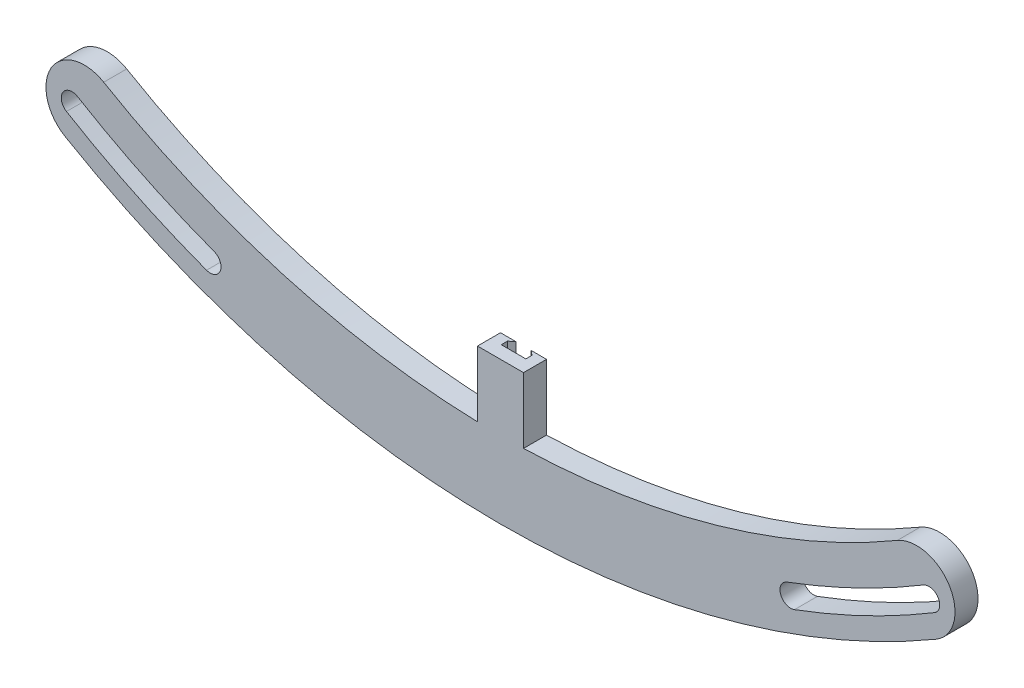
from build123d import *

# Parameters (mm, degrees)
SKETCH1_W           = 3.81
SKETCH1_H           = 12.7
SKETCH2_R           = 1.778
CUT_EXTRUDE1_DEPTH  = 15.24
SKETCH3_R           = 1.778
CUT_EXTRUDE2_DEPTH  = 4.81
SKETCH6_W           = 7.62
SKETCH6_H           = 3.81
BOSS_EXTRUDE1_DEPTH = 10.922
CUT_EXTRUDE3_DEPTH  = 6.096


with BuildPart() as part:
    # Sketch1 → Revolve1 (revolve)
    with BuildSketch(Plane(origin=(0, 0, 0), x_dir=(0, 0, -1), z_dir=(1, 0, 0)), mode=Mode.PRIVATE) as revolve1_sk:
        with Locations((-1.905, 136.398)):
            Rectangle(SKETCH1_W, SKETCH1_H)
    revolve(revolve1_sk.sketch.rotate(Axis((0, 0, 0), (0, 0, -1)), 90), axis=Axis((0, 0, 0), (0, 0, -1)))  # turned: the seam where the file's is

    # Sketch2 → Cut-Extrude1 (cut, symmetric)
    with BuildSketch(Plane.XY.offset(3.81)):
        with Locations((0, 137.668)):
            Circle(SKETCH2_R)
        with Locations((107.633176528, 85.834594042)):
            Circle(SKETCH2_R)
        with Locations((134.216375814, -30.634011936)):
            Circle(SKETCH2_R)
        with Locations((59.731906597, -124.034582106)):
            Circle(SKETCH2_R)
        with Locations((-59.731906597, -124.034582106)):
            Circle(SKETCH2_R)
        with Locations((-134.216375814, -30.634011936)):
            Circle(SKETCH2_R)
        with Locations((-107.633176528, 85.834594042)):
            Circle(SKETCH2_R)
    extrude(amount=CUT_EXTRUDE1_DEPTH, both=True, mode=Mode.SUBTRACT)

    # Sketch3 → Cut-Extrude2 (cut, through all)
    with BuildSketch(Plane.XY.offset(3.81)):
        with BuildLine():
            ThreePointArc((-70.003567413, -116.471424175), (-72.443427116, -117.079414825), (-71.835436467, -119.519274528))
            ThreePointArc((-71.835436467, -119.519274528), (-66.24004713, -122.708773411), (-60.503351759, -125.636504814))
            ThreePointArc((-60.503351759, -125.636504814), (-61.333829237, -123.263136804), (-58.960461155, -122.432659533))
            ThreePointArc((-58.960461155, -122.432659533), (-64.550865586, -119.579587941), (-70.003567413, -116.471424175))
        make_face()
        with BuildLine():
            ThreePointArc((-57.953906597, -124.034582106), (-58.785953505, -125.540057695), (-60.503351759, -125.636504814))
            ThreePointArc((-60.503351759, -125.636504814), (-54.637588239, -128.296223122), (-48.655269538, -130.68225458))
            ThreePointArc((-48.655269538, -130.68225458), (-46.36863444, -129.636373168), (-47.414515852, -127.34973807))
            ThreePointArc((-47.414515852, -127.34973807), (-53.244279962, -125.024552594), (-58.960461155, -122.432659533))
            ThreePointArc((-58.960461155, -122.432659533), (-58.226430925, -123.088629147), (-57.953906597, -124.034582106))
        make_face()
        with BuildLine():
            ThreePointArc((47.414515852, -127.34973807), (46.36863444, -129.636373168), (48.655269538, -130.68225458))
            ThreePointArc((48.655269538, -130.68225458), (54.637588297, -128.296223097), (60.503351873, -125.636504759))
            ThreePointArc((60.503351873, -125.636504759), (58.129983953, -124.806027402), (58.960461282, -122.432659472))
            ThreePointArc((58.960461282, -122.432659472), (53.244280027, -125.024552566), (47.414515852, -127.34973807))
        make_face()
        with BuildLine():
            ThreePointArc((61.509906597, -124.034582106), (61.23738222, -124.980535144), (60.503351873, -125.636504759))
            ThreePointArc((60.503351873, -125.636504759), (66.240047187, -122.708773381), (71.835436467, -119.519274528))
            ThreePointArc((71.835436467, -119.519274528), (72.443427116, -117.079414825), (70.003567413, -116.471424175))
            ThreePointArc((70.003567413, -116.471424175), (64.550865648, -119.579587907), (58.960461282, -122.432659472))
            ThreePointArc((58.960461282, -122.432659472), (60.677859616, -122.529106472), (61.509906597, -124.034582106))
        make_face()
        with BuildLine():
            ThreePointArc((-72.088346147, -123.208205302), (-74.362361234, -114.520636287), (-65.67479222, -112.2466212))
            ThreePointArc((-65.67479222, -112.2466212), (-64.697785609, 112.812582815), (130.048, 0))
            ThreePointArc((130.048, 0), (112.812582815, -64.697785609), (65.67479222, -112.2466212))
            ThreePointArc((65.67479222, -112.2466212), (74.362361234, -114.520636287), (72.088346147, -123.208205302))
            ThreePointArc((72.088346147, -123.208205302), (123.829436605, -71.015928735), (142.748, 0))
            ThreePointArc((142.748, 0), (-71.015928735, 123.829436605), (-72.088346147, -123.208205302))
        make_face()
        with Locations((-134.216375814, -30.634011936)):
            Circle(SKETCH3_R, mode=Mode.SUBTRACT)
        with Locations((134.216375814, -30.634011936)):
            Circle(SKETCH3_R, mode=Mode.SUBTRACT)
        with Locations((-107.633176528, 85.834594042)):
            Circle(SKETCH3_R, mode=Mode.SUBTRACT)
        with Locations((0, 137.668)):
            Circle(SKETCH3_R, mode=Mode.SUBTRACT)
        with Locations((107.633176528, 85.834594042)):
            Circle(SKETCH3_R, mode=Mode.SUBTRACT)
    extrude(amount=-CUT_EXTRUDE2_DEPTH, mode=Mode.SUBTRACT)

    # Sketch6 → Boss-Extrude1 (add)
    with BuildSketch(Plane.XZ.offset(130.048)):
        with Locations((0, 1.905)):
            Rectangle(SKETCH6_W, SKETCH6_H)
    extrude(amount=-BOSS_EXTRUDE1_DEPTH)

    # Sketch7 → Cut-Extrude3 (cut)
    with BuildSketch(Plane(origin=(0, -119.126, 0), x_dir=(1, 0, 0), z_dir=(0, 1, 0))):
        Polygon((-1.27, 0), (-2.032, -0.635), (-2.032, -1.651), (2.032, -1.651), (2.032, -0.635), (1.27, 0), align=None)
    extrude(amount=-CUT_EXTRUDE3_DEPTH, mode=Mode.SUBTRACT)


solid = part.part
